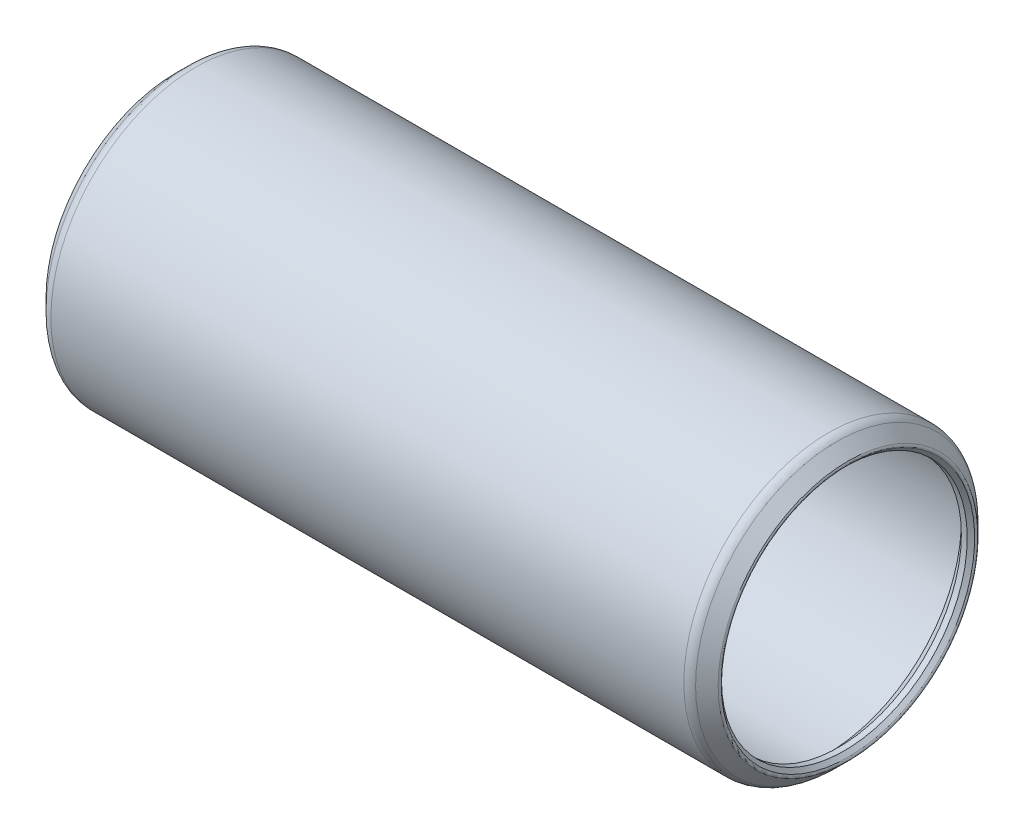
from build123d import *


with BuildPart() as part:
    # Sketch1 → Revolve1 (revolve)
    with BuildSketch(Plane.XY):
        with BuildLine():
            Line((-0.517960245, 6.836210245), (-0.3175, 6.63575))
            Line((-0.3175, 6.63575), (0, 6.63575))
            Line((0, 6.63575), (0.635, 7.27075))
            Line((0.635, 7.27075), (34.6202, 7.27075))
            Line((34.6202, 7.27075), (35.2552, 6.63575))
            Line((35.2552, 6.63575), (35.5727, 6.63575))
            Line((35.5727, 6.63575), (35.773160245, 6.836210245))
            ThreePointArc((35.773160245, 6.836210245), (35.810357684, 6.926012806), (35.773160245, 7.015815367))
            Line((35.773160245, 7.015815367), (35.164462806, 7.624512806))
            ThreePointArc((35.164462806, 7.624512806), (34.95845398, 7.762163503), (34.71545, 7.8105))
            Line((34.71545, 7.8105), (0.53975, 7.8105))
            ThreePointArc((0.53975, 7.8105), (0.29674602, 7.762163503), (0.090737194, 7.624512806))
            Line((0.090737194, 7.624512806), (-0.517960245, 7.015815367))
            ThreePointArc((-0.517960245, 7.015815367), (-0.555157684, 6.926012806), (-0.517960245, 6.836210245))
        make_face()
    revolve(axis=Axis((35.2552, 0, 0), (-1, 0, 0)))


solid = part.part
